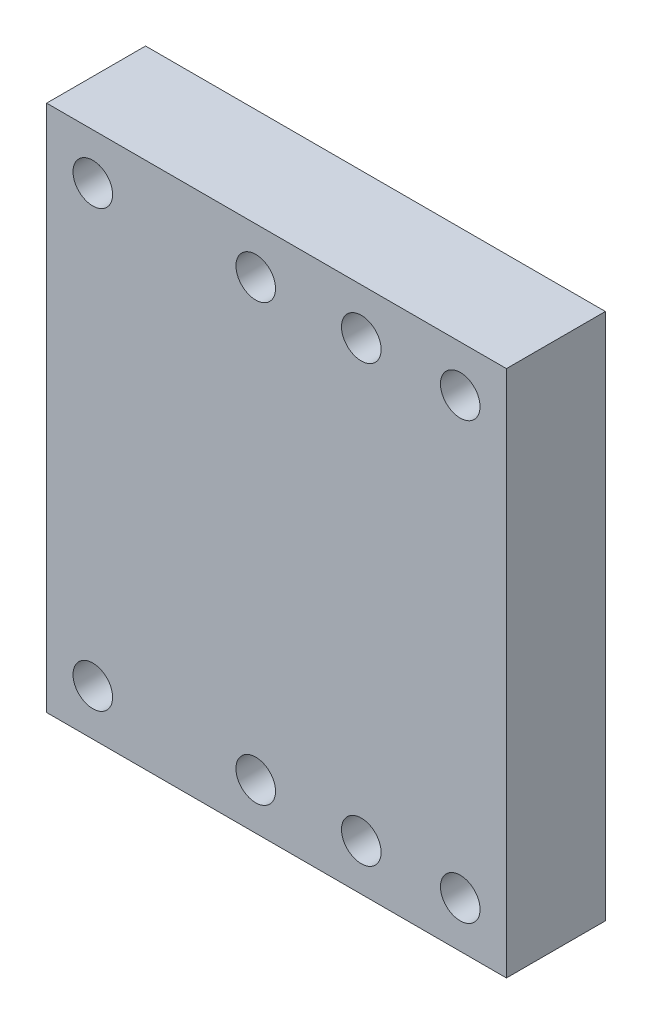
from build123d import *

# Parameters (mm, degrees)
SZKIC1_W                    = 69.7
SZKIC1_H                    = 80
DODANIE_WYCI_GNI_CIE1_DEPTH = 15
SZKIC3_R                    = 3
WYTNIJ_WYCI_GNI_CIE1_DEPTH  = 15
SZKIC4_R                    = 5
WYTNIJ_WYCI_GNI_CIE2_DEPTH  = 7
SZKIC5_R                    = 3
WYTNIJ_WYCI_GNI_CIE3_DEPTH  = 15


with BuildPart() as part:
    # Szkic1 → Dodanie-wyciągnięcie1 (new body)
    with BuildSketch(Plane.XY):
        Rectangle(SZKIC1_W, SZKIC1_H)
    extrude(amount=DODANIE_WYCI_GNI_CIE1_DEPTH)

    # Szkic3 → Wytnij-wyciągnięcie1 (cut)
    with BuildSketch(Plane(origin=(0, 0, 0), x_dir=(1, 0, 0), z_dir=(0, 0, -1))):
        with Locations((12.85, 33)):
            Circle(SZKIC3_R)
        with Locations((-3.15, 33)):
            Circle(SZKIC3_R)
        with Locations((-3.15, -33)):
            Circle(SZKIC3_R)
        with Locations((12.85, -33)):
            Circle(SZKIC3_R)
    extrude(amount=-WYTNIJ_WYCI_GNI_CIE1_DEPTH, mode=Mode.SUBTRACT)

    # Szkic4 → Wytnij-wyciągnięcie2 (cut)
    with BuildSketch(Plane(origin=(0, 0, 0), x_dir=(-1, 0, 0), z_dir=(0, 0, 1))):
        with Locations((3.15, 33)):
            Circle(SZKIC4_R)
        with Locations((-12.85, 33)):
            Circle(SZKIC4_R)
        with Locations((-12.85, -33)):
            Circle(SZKIC4_R)
        with Locations((3.15, -33)):
            Circle(SZKIC4_R)
    extrude(amount=WYTNIJ_WYCI_GNI_CIE2_DEPTH, mode=Mode.SUBTRACT)

    # Szkic5 → Wytnij-wyciągnięcie3 (cut)
    with BuildSketch(Plane.XY.offset(15)):
        with Locations((-27.85, 33)):
            Circle(SZKIC5_R)
        with Locations((27.85, 33)):
            Circle(SZKIC5_R)
        with Locations((27.85, -33)):
            Circle(SZKIC5_R)
        with Locations((-27.85, -33)):
            Circle(SZKIC5_R)
    extrude(amount=-WYTNIJ_WYCI_GNI_CIE3_DEPTH, mode=Mode.SUBTRACT)


solid = part.part
